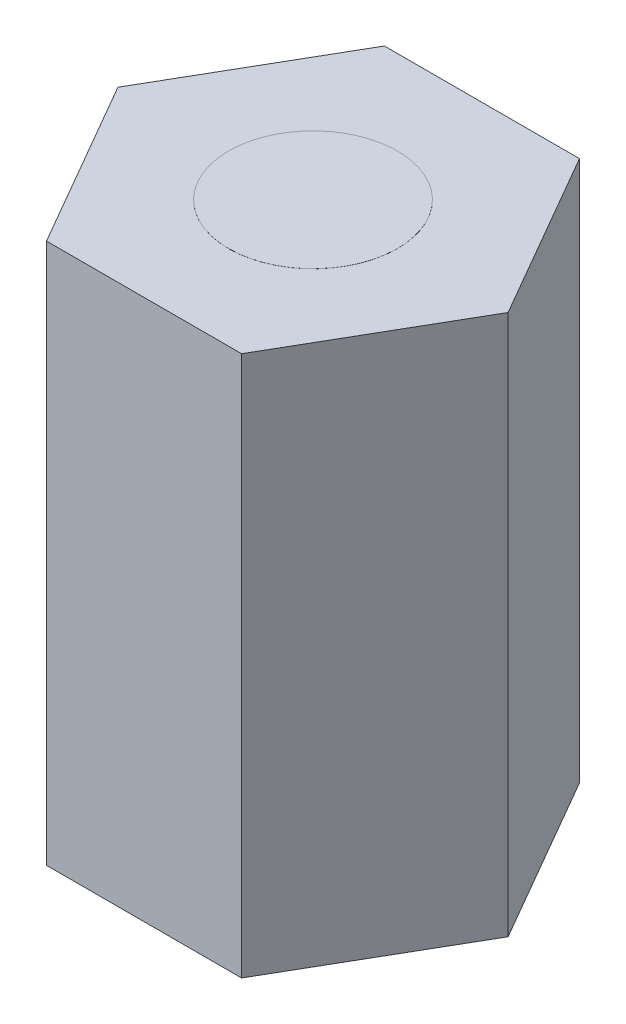
from build123d import *

# Parameters (mm, degrees)
BOSS_EXTRUDE1_DEPTH = 8
SKETCH2_R           = 1.25
BOSS_EXTRUDE2_DEPTH = 0.001


with BuildPart() as part:
    # Sketch1 → Boss-Extrude1 (new body)
    with BuildSketch(Plane(origin=(0, 0, 0), x_dir=(1, 0, 0), z_dir=(0, 1, 0))):
        Polygon((-2.886751346, 0), (-1.443375673, -2.5), (1.443375673, -2.5), (2.886751346, 0), (1.443375673, 2.5), (-1.443375673, 2.5), align=None)
    extrude(amount=BOSS_EXTRUDE1_DEPTH)

    # Sketch2 → Boss-Extrude2 (add)
    with BuildSketch(Plane(origin=(0, 8, 0), x_dir=(1, 0, 0), z_dir=(0, 1, 0))):
        Circle(SKETCH2_R)
    extrude(amount=BOSS_EXTRUDE2_DEPTH)


solid = part.part
